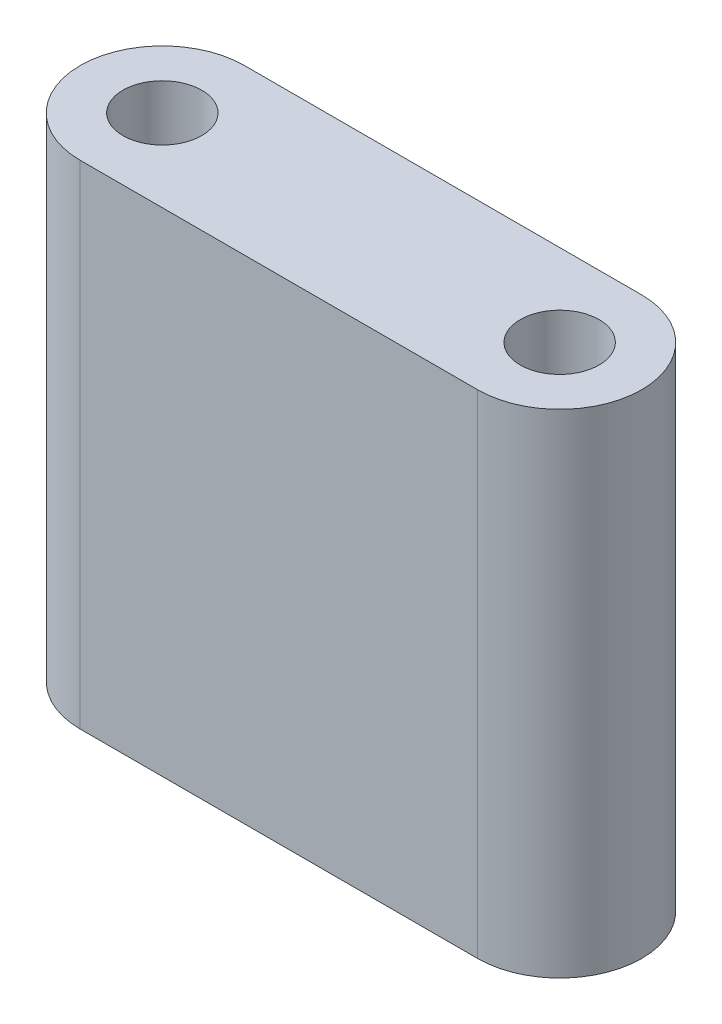
from build123d import *

# Parameters (mm, degrees)
SKETCH_1_R      = 1.2
EXTRUDE_1_DEPTH = 15
SKETCH_1_3_R    = 1.2
EXTRUDE_2_DEPTH = 15


with BuildPart() as part:
    # 草图1 → 凸台-拉伸1 (new body)
    with BuildSketch(Plane(origin=(0, 0, 0), x_dir=(1, 0, 0), z_dir=(0, 1, 0))):
        with BuildLine():
            ThreePointArc((-6.05, 2.5), (-8.55, 0), (-6.05, -2.5))
            Line((-6.05, -2.5), (6.05, -2.5))
            ThreePointArc((6.05, -2.5), (8.55, 0), (6.05, 2.5))
            Line((6.05, 2.5), (-6.05, 2.5))
        make_face()
        with Locations((-6.05, 0)):
            Circle(SKETCH_1_R, mode=Mode.SUBTRACT)
        with Locations((6.05, 0)):
            Circle(SKETCH_1_R, mode=Mode.SUBTRACT)
    extrude(amount=EXTRUDE_1_DEPTH)

    # 草图1<3> → 凸台-拉伸2 (add)
    with BuildSketch(Plane(origin=(0, 0, 0), x_dir=(1, 0, 0), z_dir=(0, 1, 0))):
        with BuildLine():
            ThreePointArc((-3.55, 0), (-4.282233047, 1.767766953), (-6.05, 2.5))
            ThreePointArc((-6.05, 2.5), (-8.55, 0), (-6.05, -2.5))
            ThreePointArc((-6.05, -2.5), (-4.282233047, -1.767766953), (-3.55, 0))
        make_face()
        with Locations((-6.05, 0)):
            Circle(SKETCH_1_3_R, mode=Mode.SUBTRACT)
    extrude(amount=EXTRUDE_2_DEPTH)


solid = part.part
